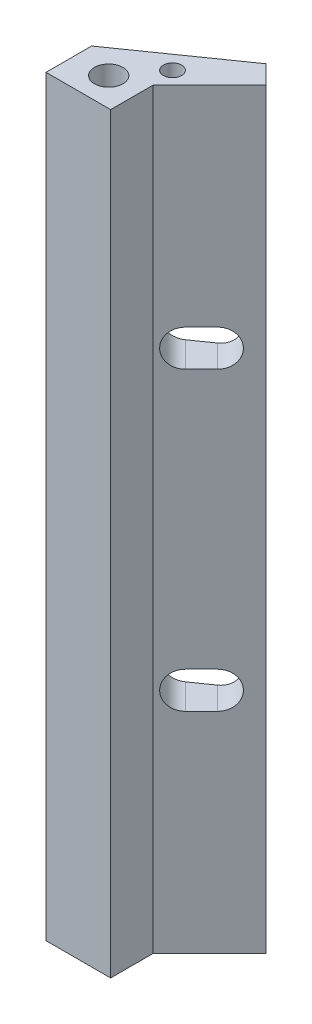
from build123d import *

# Parameters (mm, degrees)
BOSS_EXTRUDE1_DEPTH             = 66
CUT_EXTRUDE1_DEPTH              = 9.653149759
CUT_EXTRUDE2_REACH              = 10.653
F_2_5_2_5_DIAMETER_HOLE1_D      = 2.5
F_2_5_2_5_DIAMETER_HOLE1_DEPTH  = 8
F_2_5_2_5_DIAMETER_HOLE1_TIP    = 0.751075774
TAP_DRILL_FOR_M2X0_4_TAP1_D     = 1.6
TAP_DRILL_FOR_M2X0_4_TAP1_DEPTH = 8
TAP_DRILL_FOR_M2X0_4_TAP1_TIP   = 0.480688495
F_2_5_2_5_DIAMETER_HOLE2_D      = 2.5
F_2_5_2_5_DIAMETER_HOLE2_DEPTH  = 8
F_2_5_2_5_DIAMETER_HOLE2_TIP    = 0.751075774
TAP_DRILL_FOR_M2X0_4_TAP2_D     = 1.6
TAP_DRILL_FOR_M2X0_4_TAP2_DEPTH = 8
TAP_DRILL_FOR_M2X0_4_TAP2_TIP   = 0.480688495


with BuildPart() as part:
    # Sketch1 → Boss-Extrude1 (new body)
    with BuildSketch(Plane(origin=(0, 66, 0), x_dir=(1, 0, 0), z_dir=(0, 1, 0))):
        Polygon((2.999999997, 0.701867841), (-6, -5.599999997), (-6, -9.6), (-0.331046591, -9.6), (-0.331046591, -5.866580498), (4.618700872, -0.916833034), align=None)
    extrude(amount=-BOSS_EXTRUDE1_DEPTH)

    # Sketch2 → Cut-Extrude1 (cut, through all)
    with BuildSketch(Plane(origin=(2.767766953, 0, 2.767766953), x_dir=(0.707106781, 0, -0.707106781), z_dir=(0.707106781, 0, 0.707106781))):
        with BuildLine():
            Line((-0.382384145, 47.599999993), (-2.382384145, 47.599999993))
            ThreePointArc((-2.382384145, 47.599999993), (-3.982384137, 46.000000001), (-2.382384145, 44.400000009))
            Line((-2.382384145, 44.400000009), (-0.382384145, 44.400000009))
            ThreePointArc((-0.382384145, 44.400000009), (1.217615847, 46.000000001), (-0.382384145, 47.599999993))
        make_face()
    extrude(amount=-CUT_EXTRUDE1_DEPTH, mode=Mode.SUBTRACT)

    # Sketch3 → Cut-Extrude2 (cut, up to next)
    with BuildSketch(Plane(origin=(2.767766953, 0, 2.767766953), x_dir=(0.707106781, 0, -0.707106781), z_dir=(0.707106781, 0, 0.707106781)), mode=Mode.PRIVATE) as cut_extrude2_sk1:
        with BuildLine():
            Line((-0.382384145, 21.599999991), (-2.382384145, 21.599999991))
            ThreePointArc((-2.382384145, 21.599999991), (-3.982384137, 19.999999999), (-2.382384145, 18.400000007))
            Line((-2.382384145, 18.400000007), (-0.382384145, 18.400000007))
            ThreePointArc((-0.382384145, 18.400000007), (1.217615847, 19.999999999), (-0.382384145, 21.599999991))
        make_face()
    cut_extrude2_tool1 = extrude(cut_extrude2_sk1.sketch, amount=-CUT_EXTRUDE2_REACH, mode=Mode.PRIVATE) & part.part
    add(cut_extrude2_tool1.solids().sort_by_distance((1.790274, 20, 3.74526))[0], mode=Mode.SUBTRACT)

    # Ø2.5 (2.5) Diameter Hole1
    with Locations(Plane(origin=(0, 0, 0), x_dir=(-1, 0, 0), z_dir=(0, -1, 0))):
        with Locations((3, -7.1)):
            Hole(F_2_5_2_5_DIAMETER_HOLE1_D / 2, depth=F_2_5_2_5_DIAMETER_HOLE1_DEPTH)
            with Locations((0, 0, -(F_2_5_2_5_DIAMETER_HOLE1_DEPTH + F_2_5_2_5_DIAMETER_HOLE1_TIP / 2))):  # 118° drill point
                Cone(0, F_2_5_2_5_DIAMETER_HOLE1_D / 2, F_2_5_2_5_DIAMETER_HOLE1_TIP, mode=Mode.SUBTRACT)

    # Tap Drill for M2x0.4 Tap1
    with Locations(Plane(origin=(0, 0, 0), x_dir=(-1, 0, 0), z_dir=(0, -1, 0))):
        with Locations((0.604004818, -3.897000298)):
            Hole(TAP_DRILL_FOR_M2X0_4_TAP1_D / 2, depth=TAP_DRILL_FOR_M2X0_4_TAP1_DEPTH)
            with Locations((0, 0, -(TAP_DRILL_FOR_M2X0_4_TAP1_DEPTH + TAP_DRILL_FOR_M2X0_4_TAP1_TIP / 2))):  # 118° drill point
                Cone(0, TAP_DRILL_FOR_M2X0_4_TAP1_D / 2, TAP_DRILL_FOR_M2X0_4_TAP1_TIP, mode=Mode.SUBTRACT)

    # Ø2.5 (2.5) Diameter Hole2
    with Locations(Plane(origin=(0, 66, 0), x_dir=(1, 0, 0), z_dir=(0, 1, 0))):
        with Locations((-3, -7.1)):
            Hole(F_2_5_2_5_DIAMETER_HOLE2_D / 2, depth=F_2_5_2_5_DIAMETER_HOLE2_DEPTH)
            with Locations((0, 0, -(F_2_5_2_5_DIAMETER_HOLE2_DEPTH + F_2_5_2_5_DIAMETER_HOLE2_TIP / 2))):  # 118° drill point
                Cone(0, F_2_5_2_5_DIAMETER_HOLE2_D / 2, F_2_5_2_5_DIAMETER_HOLE2_TIP, mode=Mode.SUBTRACT)

    # Tap Drill for M2x0.4 Tap2
    with Locations(Plane(origin=(0, 66, 0), x_dir=(1, 0, 0), z_dir=(0, 1, 0))):
        with Locations((-0.604004818, -3.897000298)):
            Hole(TAP_DRILL_FOR_M2X0_4_TAP2_D / 2, depth=TAP_DRILL_FOR_M2X0_4_TAP2_DEPTH)
            with Locations((0, 0, -(TAP_DRILL_FOR_M2X0_4_TAP2_DEPTH + TAP_DRILL_FOR_M2X0_4_TAP2_TIP / 2))):  # 118° drill point
                Cone(0, TAP_DRILL_FOR_M2X0_4_TAP2_D / 2, TAP_DRILL_FOR_M2X0_4_TAP2_TIP, mode=Mode.SUBTRACT)


solid = part.part
